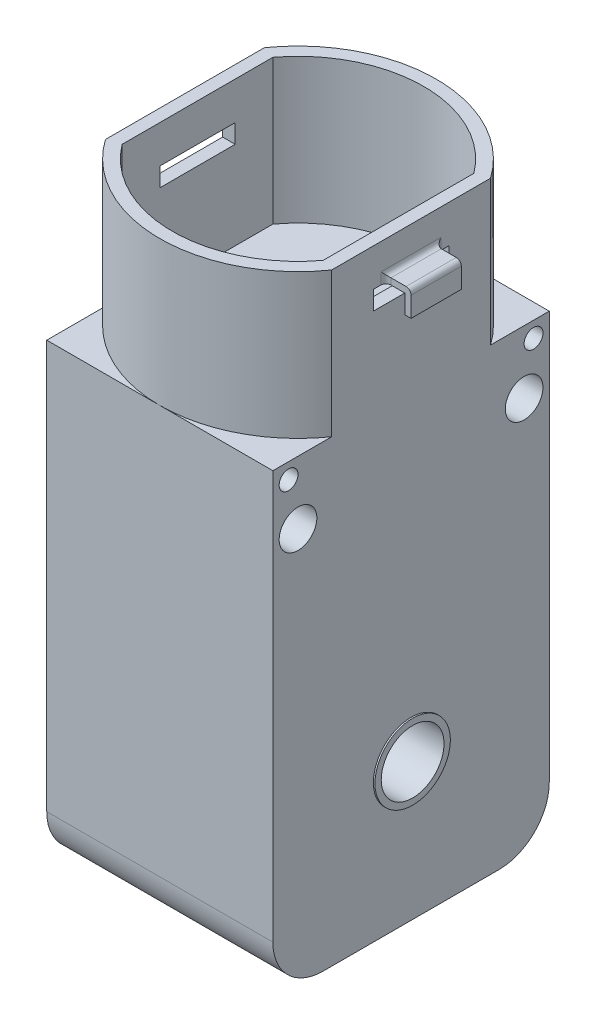
from build123d import *
from build123d.topology import SkipClean

# Parameters (mm, degrees)
SKETCH1_W           = 18
SKETCH1_H           = 22
BOSS_EXTRUDE1_DEPTH = 36.5
FILLET1_R           = 4
BOSS_EXTRUDE2_DEPTH = 11.5
BOSS_EXTRUDE3_DEPTH = 2
SKETCH4_W           = 6
SKETCH4_H           = 1.5
CUT_EXTRUDE1_DEPTH  = 4
FILLET2_R           = 0.4
FILLET3_R           = 0.4
FILLET4_R           = 0.4
SKETCH5_R           = 1.5
CUT_EXTRUDE2_DEPTH  = 54.150729064
SKETCH5_3_R         = 1.5
SKETCH5_3_R_2       = 2.45
SKETCH5_3_R_3       = 2
CUT_EXTRUDE3_DEPTH  = 1
SKETCH6_R           = 0.75
CUT_EXTRUDE4_DEPTH  = 9
SKETCH7_R           = 0.75
CUT_EXTRUDE5_DEPTH  = 8
SKETCH8_R           = 2.5
CUT_EXTRUDE6_DEPTH  = 54.150729064
BOSS_EXTRUDE4_START = 0.125
SKETCH8_3_R         = 3
SKETCH8_3_R_2       = 2.5
BOSS_EXTRUDE4_DEPTH = 0.125
SKETCH11_R          = 1.5
BOSS_EXTRUDE5_DEPTH = 1.25


with BuildPart() as part:
    # Sketch1 → Boss-Extrude1 (new body)
    with BuildSketch(Plane(origin=(0, 0, 0), x_dir=(1, 0, 0), z_dir=(0, 1, 0))):
        Rectangle(SKETCH1_W, SKETCH1_H)
    extrude(amount=BOSS_EXTRUDE1_DEPTH)

    # Fillet1
    fillet1_edges = [part.edges().sort_by_distance(p)[0] for p in [
        (0, 0, 11),
        (0, 0, -11),
    ]]
    fillet(fillet1_edges, radius=FILLET1_R)

    # Sketch2 → Boss-Extrude2 (add)
    with BuildSketch(Plane(origin=(0, 36.5, 0), x_dir=(1, 0, 0), z_dir=(0, 1, 0))):
        with BuildLine():
            Line((-9, 6.32455532), (-9, -6.32455532))
            ThreePointArc((-9, -6.32455532), (0, -11), (9, -6.32455532))
            Line((9, -6.32455532), (9, 6.32455532))
            ThreePointArc((9, 6.32455532), (0, 11), (-9, 6.32455532))
        make_face()
        with BuildLine():
            Line((-8, 6), (-8, -6))
            ThreePointArc((-8, -6), (0, -10), (8, -6))
            Line((8, -6), (8, 6))
            ThreePointArc((8, 6), (0, 10), (-8, 6))
        make_face(mode=Mode.SUBTRACT)
    extrude(amount=BOSS_EXTRUDE2_DEPTH)

    # Sketch3 → Boss-Extrude3 (add, symmetric)
    with BuildSketch(Plane.XY):
        Polygon((-9, 45), (-10.5, 45), (-10.5, 43.5), (-11, 43.5), (-11, 45.5), (-9, 45.5), align=None)
    boss_extrude3 = extrude(amount=BOSS_EXTRUDE3_DEPTH, both=True)

    # Sketch4 → Cut-Extrude1 (cut)
    with BuildSketch(Plane.ZY.offset(9)):
        with Locations((0, 44.25)):
            Rectangle(SKETCH4_W, SKETCH4_H)
    cut_extrude1 = extrude(amount=-CUT_EXTRUDE1_DEPTH, mode=Mode.SUBTRACT)

    # Fillet2
    fillet2_edges = [part.edges().sort_by_distance(p)[0] for p in [
        (-9, 45.25, -2),
        (-9, 45.5, 0),
        (-9, 45.25, 2),
    ]]
    fillet(fillet2_edges, radius=FILLET2_R)

    # Fillet3
    fillet3_edges = [part.edges().sort_by_distance(p)[0] for p in [
        (-11, 45.5, 0),
    ]]
    fillet(fillet3_edges, radius=FILLET3_R)

    # Mirror1: Boss-Extrude3, Cut-Extrude1 across plane
    add(boss_extrude3.mirror(Plane(origin=(0, 0, 0), x_dir=(0, 0, 1), z_dir=(1, 0, 0))))
    add(cut_extrude1.mirror(Plane(origin=(0, 0, 0), x_dir=(0, 0, 1), z_dir=(1, 0, 0))), mode=Mode.SUBTRACT)

    # Fillet4
    fillet4_edges = [part.edges().sort_by_distance(p)[0] for p in [
        (9, 45.25, 2),
        (9, 45.5, 0),
        (11, 45.5, 0),
        (9, 45.25, -2),
    ]]
    fillet(fillet4_edges, radius=FILLET4_R)

    # Sketch5 → Cut-Extrude2 (cut, through all)
    with BuildSketch(Plane.ZY.offset(9)):
        with Locations((9, 31.5)):
            Circle(SKETCH5_R)
    cut_extrude2 = extrude(amount=-CUT_EXTRUDE2_DEPTH, mode=Mode.SUBTRACT)

    # Sketch5_3 → Cut-Extrude3 (cut)
    # profile 1 of 5: a face of its own
    with BuildSketch(Plane.ZY.offset(9)):
        with Locations((9, 31.5)):
            Circle(SKETCH5_3_R)
    # profile 2 of 5: a face of its own
    with BuildSketch(Plane.ZY.offset(9)):
        with Locations((6, 34)):
            Circle(SKETCH5_3_R_2)
        with Locations((6, 34)):
            Circle(SKETCH5_3_R_3, mode=Mode.SUBTRACT)
    # profile 3 of 5: a face of its own
    with BuildSketch(Plane.ZY.offset(9)):
        with Locations((6, 34)):
            Circle(SKETCH5_3_R_3)
    # profile 4 of 5: a face of its own
    with BuildSketch(Plane.ZY.offset(9)):
        with Locations((9, 31.5)):
            Circle(SKETCH5_3_R)
    # profile 5 of 5: a face of its own
    with BuildSketch(Plane.ZY.offset(9)):
        with Locations((6, 34)):
            Circle(SKETCH5_3_R_2)
    cut_extrude3 = extrude(amount=-CUT_EXTRUDE3_DEPTH, mode=Mode.SUBTRACT)

    # Sketch6 → Cut-Extrude4 (cut)
    with BuildSketch(Plane.ZY.offset(8)):
        with Locations((6, 34)):
            Circle(SKETCH6_R)
    cut_extrude4 = extrude(amount=-CUT_EXTRUDE4_DEPTH, mode=Mode.SUBTRACT)

    # Mirror4: Cut-Extrude2, Cut-Extrude3, Cut-Extrude4 across plane
    add(cut_extrude2.mirror(Plane.XY), mode=Mode.SUBTRACT)
    add(cut_extrude3.mirror(Plane.XY), mode=Mode.SUBTRACT)
    add(cut_extrude4.mirror(Plane.XY), mode=Mode.SUBTRACT)

    # Sketch7 → Cut-Extrude5 (cut)
    with BuildSketch(Plane(origin=(9, 0, 0), x_dir=(0, 0, -1), z_dir=(1, 0, 0))):
        with Locations((-9.75, 35.25)):
            Circle(SKETCH7_R)
    cut_extrude5 = extrude(amount=-CUT_EXTRUDE5_DEPTH, mode=Mode.SUBTRACT)

    # Mirror5: Cut-Extrude5 across plane
    add(cut_extrude5.mirror(Plane.XY), mode=Mode.SUBTRACT)

    # Sketch8 → Cut-Extrude6 (cut, through all)
    with BuildSketch(Plane.ZY.offset(9)):
        with Locations((0, 11)):
            Circle(SKETCH8_R)
    extrude(amount=-CUT_EXTRUDE6_DEPTH, mode=Mode.SUBTRACT)

    # Sketch8_3 → Boss-Extrude4 (add)
    with BuildSketch(Plane.ZY.offset(9).offset(BOSS_EXTRUDE4_START)):
        with Locations(Location((0, 11, 0), (0, 0, 180))):
            Circle(SKETCH8_3_R)
        with Locations((0, 11)):
            Circle(SKETCH8_3_R_2, mode=Mode.SUBTRACT)
    boss_extrude4 = extrude(amount=-BOSS_EXTRUDE4_DEPTH)

    # Sketch9 → Revolve1 (revolve)
    with SkipClean():  # the faces are left unmerged after this step: merging them gives an invalid solid
        with BuildSketch(Plane(origin=(0, 22, 0), x_dir=(-1, 0, 0), z_dir=(0, -1, 0))):
            with BuildLine():
                Line((9, 1.5), (9, -1.5))
                ThreePointArc((9, -1.5), (10.5, 0), (9, 1.5))
            make_face()
        revolve(axis=Axis((-9, 22, -1.5), (0, 0, 1)))

    # Mirror6: Boss-Extrude4 across plane
    with SkipClean():  # the faces are left unmerged after this step: merging them gives an invalid solid
        add(boss_extrude4.mirror(Plane(origin=(0, 0, 0), x_dir=(0, 0, 1), z_dir=(1, 0, 0))))

    # Sketch11 → Boss-Extrude5 (add, symmetric)
    with SkipClean():  # the faces are left unmerged after this step: merging them gives an invalid solid
        with BuildSketch(Plane(origin=(0, 0, 0), x_dir=(0, 0, -1), z_dir=(1, 0, 0))):
            Polygon((-2.5, -2.810816006), (-2.5, 0), (2.5, 0), (2.5, -2.810816006), (2.5, -5), (-2.5, -5), align=None)
            with Locations((0, -2.5)):
                Circle(SKETCH11_R, mode=Mode.SUBTRACT)
        extrude(amount=BOSS_EXTRUDE5_DEPTH, both=True)


solid = part.part
